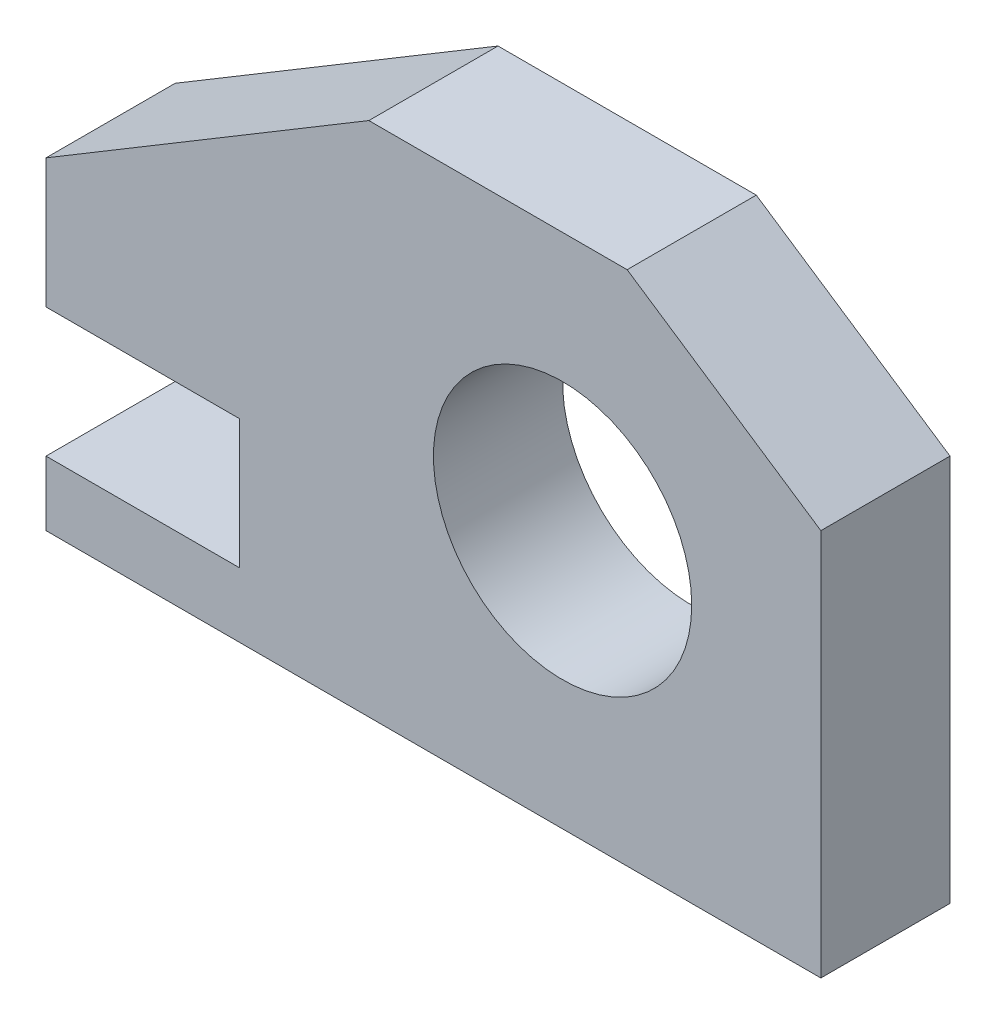
from build123d import *

# Parameters (mm, degrees)
BOSS_EXTRUDE1_DEPTH = 12.7
SKETCH2_R           = 12.7
CUT_EXTRUDE1_DEPTH  = 13.7


with BuildPart() as part:
    # Sketch1 → Boss-Extrude1 (new body)
    with BuildSketch(Plane.XY):
        Polygon((0, 0), (76.2, 0), (76.2, 38.1), (57.15, 50.8), (31.75, 50.8), (0, 31.75), (0, 19.05), (19.05, 19.05), (19.05, 6.35), (0, 6.35), align=None)
    extrude(amount=BOSS_EXTRUDE1_DEPTH)

    # Sketch2 → Cut-Extrude1 (cut, through all)
    with BuildSketch(Plane.XY.offset(12.7)):
        with Locations((50.8, 25.4)):
            Circle(SKETCH2_R)
    extrude(amount=-CUT_EXTRUDE1_DEPTH, mode=Mode.SUBTRACT)


solid = part.part
